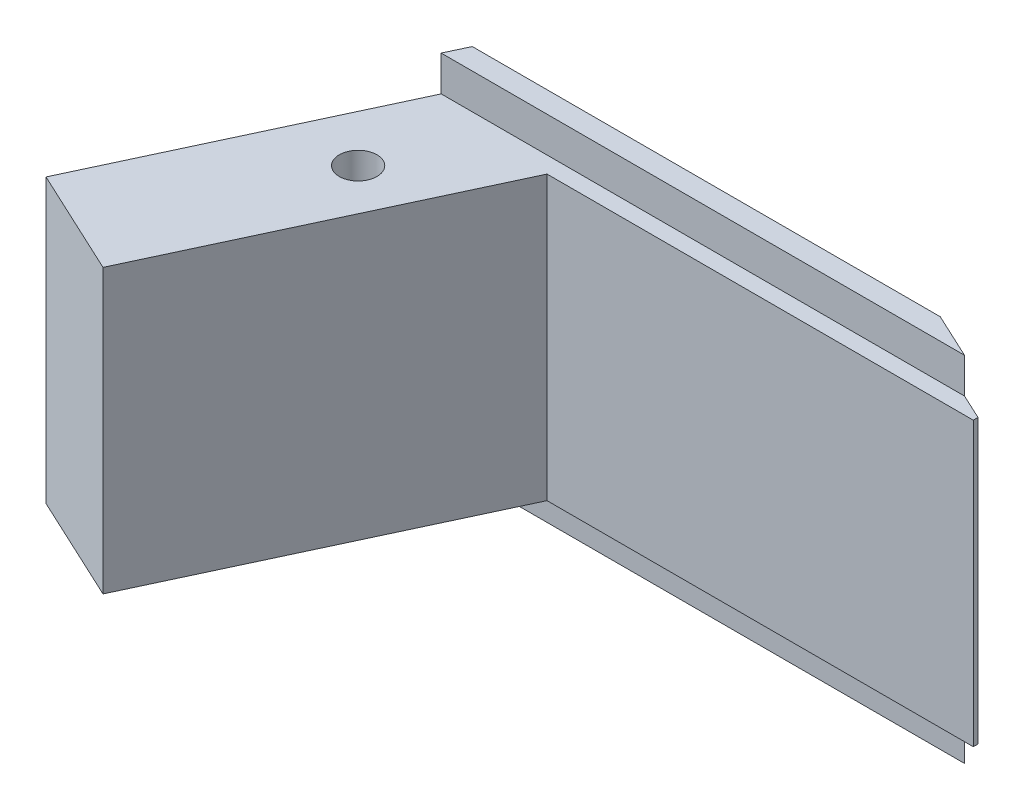
from build123d import *

# Parameters (mm, degrees)
SKETCH_1_W               = 27
SKETCH_1_H               = 15
EXTRUDE_1_DEPTH          = 11
CUT_EXTRUDE_6_DEPTH      = 16
SKETCH_2_OUTSIDE_W       = 35.558
SKETCH_2_OUTSIDE_H       = 23.558
SKETCH_2_OUTSIDE_W_2     = 28.581712044
SKETCH_2_OUTSIDE_H_2     = 12
CUT_EXTRUDE_1_DEPTH      = 10.4
CUT_EXTRUDE_1_DEPTH_BACK = 0.7
SKETCH_6_W               = 5
SKETCH_6_H               = 12
EXTRUDE_2_DEPTH          = 3.803863
SKETCH_7_R               = 0.8
CUT_EXTRUDE_7_DEPTH      = 14.5


with BuildPart() as part:
    # Эскиз1 → Бобышка-Вытянуть1 (new body)
    with BuildSketch(Plane.XY):
        with Locations((13.5, 7.5)):
            Rectangle(SKETCH_1_W, SKETCH_1_H)
    extrude(amount=EXTRUDE_1_DEPTH)

    # Эскиз5 → Вырез-Вытянуть6 (cut, through all)
    with BuildSketch(Plane(origin=(0, 15, 0), x_dir=(1, 0, 0), z_dir=(0, 1, 0))):
        Polygon((0, 0), (0, -8.886908691), (4.14403358, 0), align=None)
        Polygon((27, -11), (27, -1.6), (8.914830922, -1.6), (4.531538935, -11), align=None)
        Polygon((0, -11), (4.531538935, -11), (0, -8.886908691), align=None)
        Polygon((23.997690311, 0), (27, -1.4), (27, 0), align=None)
    extrude(amount=-CUT_EXTRUDE_6_DEPTH, mode=Mode.SUBTRACT)

    # Эскиз2 outside → Вырез-Вытянуть1 (cut, two sides)
    with BuildSketch(Plane.XY.offset(1.6)) as cut_extrude_1_sk:
        with Locations((13.5, 7.5)):
            Rectangle(SKETCH_2_OUTSIDE_W, SKETCH_2_OUTSIDE_H)
        with Locations((13.459567245, 7.5)):
            Rectangle(SKETCH_2_OUTSIDE_W_2, SKETCH_2_OUTSIDE_H_2, mode=Mode.SUBTRACT)
    extrude(amount=CUT_EXTRUDE_1_DEPTH, mode=Mode.SUBTRACT)
    extrude(cut_extrude_1_sk.sketch, amount=-CUT_EXTRUDE_1_DEPTH_BACK, mode=Mode.SUBTRACT)

    # Эскиз6 → Бобышка-Вытянуть2 (add)
    with BuildSketch(Plane(origin=(-3.40388351, 0, 7.299651743), x_dir=(0.906307787, 0, 0.422618262), z_dir=(-0.422618262, 0, 0.906307787))):
        with Locations((6.255769903, 7.5)):
            Rectangle(SKETCH_6_W, SKETCH_6_H)
    extrude(amount=EXTRUDE_2_DEPTH)

    # Эскиз7 → Вырез-Вытянуть7 (cut, through all)
    with BuildSketch(Plane(origin=(0, 13.5, 0), x_dir=(1, 0, 0), z_dir=(0, 1, 0))):
        with Locations((4.598685766, -5.298008566)):
            Circle(SKETCH_7_R)
    extrude(amount=-CUT_EXTRUDE_7_DEPTH, mode=Mode.SUBTRACT)


solid = part.part
